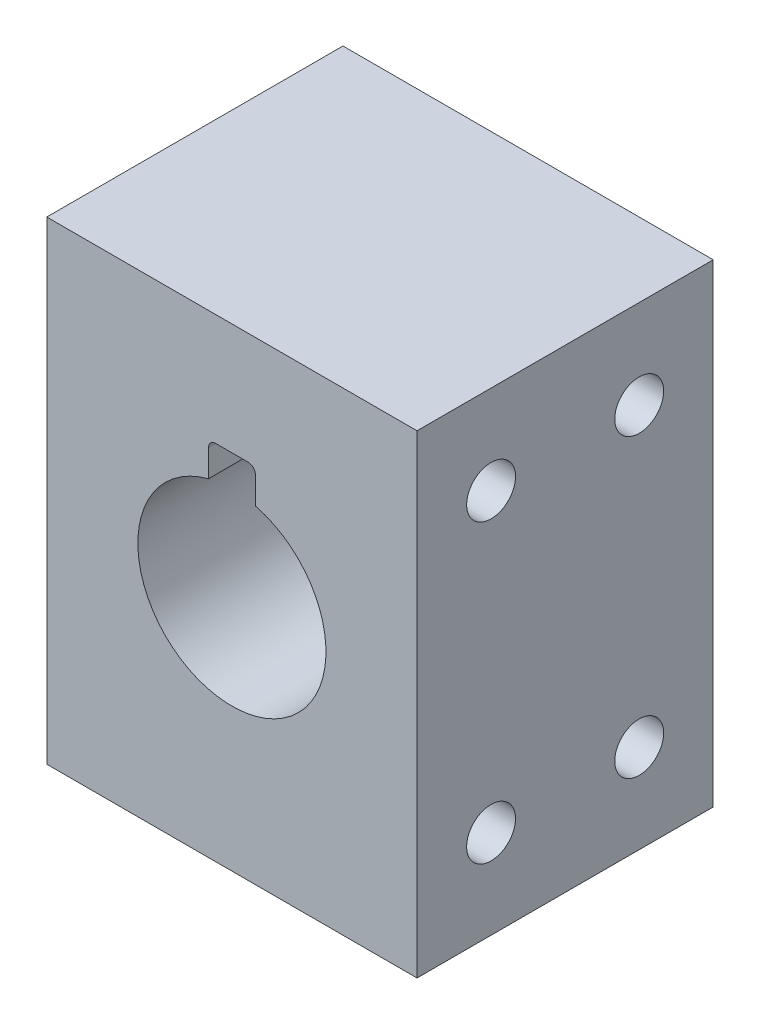
from build123d import *

# Parameters (mm, degrees)
SKETCH1_W                      = 25
SKETCH1_H                      = 32
BOSS_EXTRUDE1_DEPTH            = 20
CUT_EXTRUDE1_DEPTH             = 46.265881191
M4X0_7_TAPPED_HOLE1_AT_2_COUNT = 2
M4X0_7_TAPPED_HOLE1_AT_2_PITCH = 22.360679775
M4X0_7_TAPPED_HOLE1_AT_3_COUNT = 2
M4X0_7_TAPPED_HOLE1_AT_3_PITCH = 20
M4X0_7_TAPPED_HOLE1_AT_4_COUNT = 2
M4X0_7_TAPPED_HOLE1_AT_4_PITCH = 10
FILLET1_R                      = 0.5


with BuildPart() as part:
    # Sketch1 → Boss-Extrude1 (new body)
    with BuildSketch(Plane.XY):
        with Locations((-12.5, 16)):
            Rectangle(SKETCH1_W, SKETCH1_H)
    extrude(amount=BOSS_EXTRUDE1_DEPTH)

    # Sketch2 → Cut-Extrude1 (cut, through all)
    with BuildSketch(Plane.XY.offset(20)):
        with BuildLine():
            Line((-10.9125, 24.4625), (-14.0875, 24.4625))
            Line((-14.0875, 24.4625), (-14.0875, 22.148361062))
            ThreePointArc((-14.0875, 22.148361062), (-12.5, 9.65), (-10.9125, 22.148361062))
            Line((-10.9125, 22.148361062), (-10.9125, 24.4625))
        make_face()
    extrude(amount=-CUT_EXTRUDE1_DEPTH, mode=Mode.SUBTRACT)

    # Sketch4 → M4x0.7 Tapped Hole1 (revolve, cut)
    with BuildSketch(Plane(origin=(-25, 26, 5), x_dir=(0, 0, 1), z_dir=(0, 1, 0))):
        Polygon((0, 0), (0, 7.991420021), (1.65, 7), (1.65, 0), align=None)
    m4x0_7_tapped_hole1 = revolve(axis=Axis((-31.35, 26, 5), (1, 0, 0)), mode=Mode.SUBTRACT)

    # M4x0.7 Tapped Hole1 at 2: M4x0.7 Tapped Hole1 ×2
    with Locations(*[Vector(0, -0.894427190999916, 0.44721359549995787) * (i * M4X0_7_TAPPED_HOLE1_AT_2_PITCH) for i in range(1, M4X0_7_TAPPED_HOLE1_AT_2_COUNT)]):
        add(m4x0_7_tapped_hole1, mode=Mode.SUBTRACT)

    # M4x0.7 Tapped Hole1 at 3: M4x0.7 Tapped Hole1 ×2
    with Locations(*[(0, -i * M4X0_7_TAPPED_HOLE1_AT_3_PITCH, 0) for i in range(1, M4X0_7_TAPPED_HOLE1_AT_3_COUNT)]):
        add(m4x0_7_tapped_hole1, mode=Mode.SUBTRACT)

    # M4x0.7 Tapped Hole1 at 4: M4x0.7 Tapped Hole1 ×2
    with Locations(*[(0, 0, i * M4X0_7_TAPPED_HOLE1_AT_4_PITCH) for i in range(1, M4X0_7_TAPPED_HOLE1_AT_4_COUNT)]):
        add(m4x0_7_tapped_hole1, mode=Mode.SUBTRACT)

    # Mirror1: M4x0.7 Tapped Hole1 across plane
    add(m4x0_7_tapped_hole1.mirror(Plane.ZY.offset(12.5)), mode=Mode.SUBTRACT)

    # Mirror1 copy 1 sketch → Mirror1 copy 1 (revolve, cut)
    with BuildSketch(Plane(origin=(0, 6, 15), x_dir=(0, 0, 1), z_dir=(0, 1, 0))):
        Polygon((0, 0), (0, -7.991420021), (1.65, -7), (1.65, 0), align=None)
    revolve(axis=Axis((6.35, 6, 15), (1, 0, 0)), mode=Mode.SUBTRACT)

    # Mirror1 copy 2 sketch → Mirror1 copy 2 (revolve, cut)
    with BuildSketch(Plane(origin=(0, 6, 5), x_dir=(0, 0, 1), z_dir=(0, 1, 0))):
        Polygon((0, 0), (0, -7.991420021), (1.65, -7), (1.65, 0), align=None)
    revolve(axis=Axis((6.35, 6, 5), (1, 0, 0)), mode=Mode.SUBTRACT)

    # Mirror1 copy 3 sketch → Mirror1 copy 3 (revolve, cut)
    with BuildSketch(Plane(origin=(0, 26, 15), x_dir=(0, 0, 1), z_dir=(0, 1, 0))):
        Polygon((0, 0), (0, -7.991420021), (1.65, -7), (1.65, 0), align=None)
    revolve(axis=Axis((6.35, 26, 15), (1, 0, 0)), mode=Mode.SUBTRACT)

    # Fillet1
    fillet1_edges = [part.edges().sort_by_distance(p)[0] for p in [
        (-10.9125, 24.4625, 10),
        (-14.0875, 24.4625, 10),
    ]]
    fillet(fillet1_edges, radius=FILLET1_R)


solid = part.part
